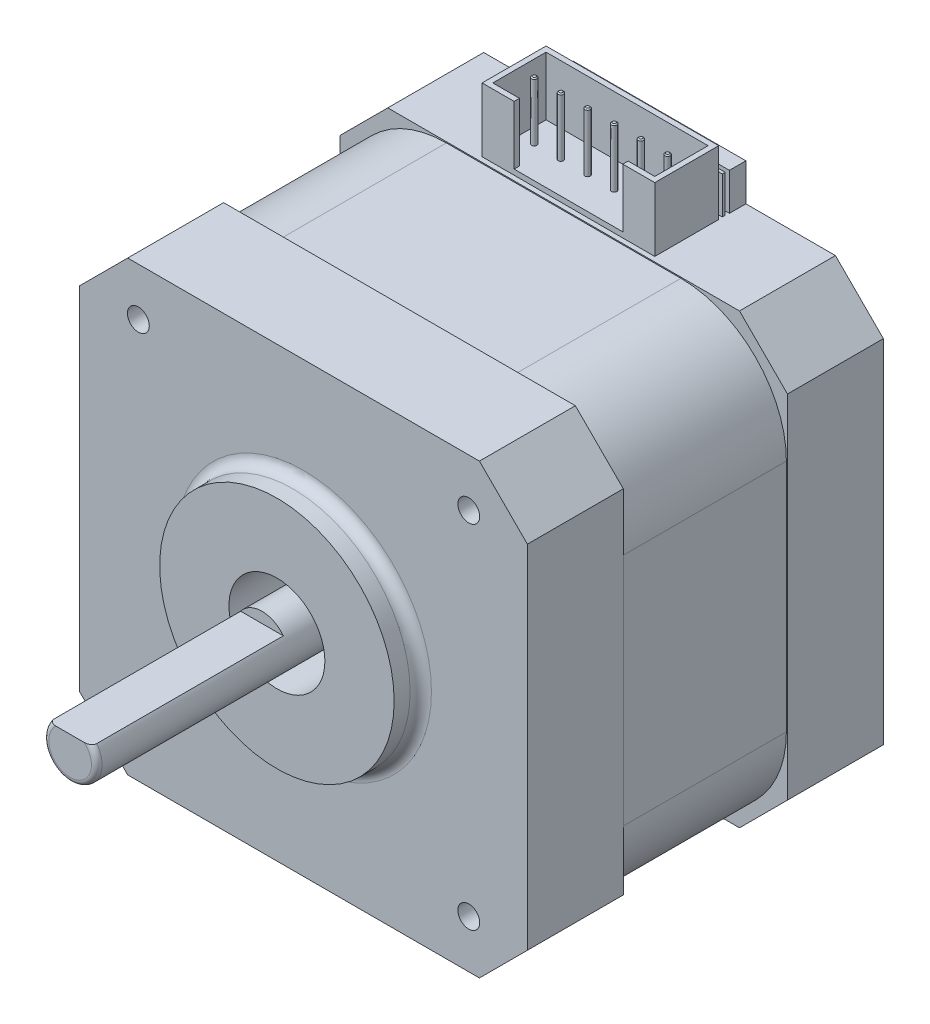
from build123d import *

# Parameters (mm, degrees)
BOSS_EXTRUDE1_DEPTH                = 9
BOSS_EXTRUDE2_DEPTH                = 15.4
BOSS_EXTRUDE3_DEPTH                = 9
SKETCH4_R                          = 4.5
CUT_EXTRUDE1_DEPTH                 = 5
SKETCH5_R                          = 2.5
BOSS_EXTRUDE4_DEPTH                = 26.9
SKETCH6_W                          = 16.2
SKETCH6_H                          = 1.547449217
BOSS_EXTRUDE5_DEPTH                = 3.5
EXTRUDE_THIN4_DEPTH                = 6
BOSS_EXTRUDE7_DEPTH                = 0.5
SKETCH9_W                          = 16.123667198
SKETCH9_H                          = 0.274090176
BOSS_EXTRUDE8_DEPTH                = 3.5
SKETCH10_R                         = 0.25
BOSS_EXTRUDE9_DEPTH                = 5.5
CHAMFER1_SIZE                      = 0.1
SKETCH11_R                         = 11
SKETCH11_R_2                       = 4.5
BOSS_EXTRUDE10_DEPTH               = 2.5
FILLET1_R                          = 1
CUT_EXTRUDE2_DEPTH                 = 18
FILLET2_R                          = 0.5
TAP_DRILL_FOR_M2_5X0_45_TAP2_D     = 2.05
TAP_DRILL_FOR_M2_5X0_45_TAP2_DEPTH = 5
TAP_DRILL_FOR_M2_5X0_45_TAP2_TIP   = 0.615882135


with BuildPart() as part:
    # Sketch1 → Boss-Extrude1 (new body)
    with BuildSketch(Plane.XY):
        Polygon((21, 16.5), (16.5, 21), (-16.5, 21), (-21, 16.5), (-21, -16.5), (-16.5, -21), (16.5, -21), (21, -16.5), align=None)
    extrude(amount=BOSS_EXTRUDE1_DEPTH)

    # Sketch2 → Boss-Extrude2 (add)
    with BuildSketch(Plane.XY.offset(9)):
        with BuildLine():
            Line((11, 20.9), (-11, 20.9))
            ThreePointArc((-11, 20.9), (-18.000357134, 18.000357134), (-20.9, 11))
            Line((-20.9, 11), (-20.9, -11))
            ThreePointArc((-20.9, -11), (-18.000357134, -18.000357134), (-11, -20.9))
            Line((-11, -20.9), (11, -20.9))
            ThreePointArc((11, -20.9), (18.000357134, -18.000357134), (20.9, -11))
            Line((20.9, -11), (20.9, 11))
            ThreePointArc((20.9, 11), (18.000357134, 18.000357134), (11, 20.9))
        make_face()
    extrude(amount=BOSS_EXTRUDE2_DEPTH)

    # Sketch3 → Boss-Extrude3 (add)
    with BuildSketch(Plane.XY.offset(24.4)):
        Polygon((21, -16.5), (21, 16.5), (16.5, 21), (-16.5, 21), (-21, 16.5), (-21, -16.5), (-16.5, -21), (16.5, -21), align=None)
    extrude(amount=BOSS_EXTRUDE3_DEPTH)

    # Sketch4 → Cut-Extrude1 (cut)
    with BuildSketch(Plane.XY.offset(33.4)):
        Circle(SKETCH4_R)
    extrude(amount=-CUT_EXTRUDE1_DEPTH, mode=Mode.SUBTRACT)

    # Sketch5 → Boss-Extrude4 (add)
    with BuildSketch(Plane.XY.offset(28.4)):
        Circle(SKETCH5_R)
    extrude(amount=BOSS_EXTRUDE4_DEPTH)

    # Sketch6 → Boss-Extrude5 (add)
    with BuildSketch(Plane(origin=(0, 21, 0), x_dir=(1, 0, 0), z_dir=(0, 1, 0))):
        with Locations((0, -0.773724609)):
            Rectangle(SKETCH6_W, SKETCH6_H)
    extrude(amount=BOSS_EXTRUDE5_DEPTH)

    # Sketch7 → Extrude-Thin4 (add)
    with BuildSketch(Plane(origin=(0, 21, 0), x_dir=(1, 0, 0), z_dir=(0, 1, 0))):
        Polygon((-5.1, -8.547449217), (-8.1, -8.547449217), (-8.1, -2.547449217), (8.1, -2.547449217), (8.1, -8.547449217), (5.1, -8.547449217), (5.1, -8.047449217), (7.6, -8.047449217), (7.6, -3.047449217), (-7.6, -3.047449217), (-7.6, -8.047449217), (-5.1, -8.047449217), align=None)
    extrude(amount=EXTRUDE_THIN4_DEPTH)

    # Sketch8 → Boss-Extrude7 (add)
    with BuildSketch(Plane(origin=(0, 21, 0), x_dir=(1, 0, 0), z_dir=(0, 1, 0))):
        Polygon((-5.1, -8.047449217), (-5.1, -8.547449217), (5.1, -8.547449217), (5.1, -8.047449217), (7.6, -8.047449217), (7.6, -3.047449217), (-7.6, -3.047449217), (-7.6, -8.047449217), align=None)
    extrude(amount=BOSS_EXTRUDE7_DEPTH)

    # Sketch9 → Boss-Extrude8 (add)
    with BuildSketch(Plane(origin=(0, 21, 0), x_dir=(1, 0, 0), z_dir=(0, 1, 0))):
        with Locations((0, -2.039705449)):
            Rectangle(SKETCH9_W, SKETCH9_H)
    extrude(amount=BOSS_EXTRUDE8_DEPTH)

    # Sketch10 → Boss-Extrude9 (add)
    with BuildSketch(Plane(origin=(0, 21.5, 0), x_dir=(1, 0, 0), z_dir=(0, 1, 0))):
        with Locations((-6.204552759, -5.547449217)):
            Circle(SKETCH10_R)
        with Locations((-3.704552759, -5.547449217)):
            Circle(SKETCH10_R)
        with Locations((-1.204552759, -5.547449217)):
            Circle(SKETCH10_R)
        with Locations((1.295447241, -5.547449217)):
            Circle(SKETCH10_R)
        with Locations((3.795447241, -5.547449217)):
            Circle(SKETCH10_R)
        with Locations((6.295447241, -5.547449217)):
            Circle(SKETCH10_R)
    extrude(amount=BOSS_EXTRUDE9_DEPTH)

    # Chamfer1
    chamfer1_edges = [part.edges().sort_by_distance(p)[0] for p in [
        (-6.454552759, 27, 5.547449217),
        (-3.954552759, 27, 5.547449217),
        (-1.454552759, 27, 5.547449217),
        (1.045447241, 27, 5.547449217),
        (3.545447241, 27, 5.547449217),
        (6.045447241, 27, 5.547449217),
    ]]
    chamfer(chamfer1_edges, length=CHAMFER1_SIZE)

    # Sketch11 → Boss-Extrude10 (add)
    with BuildSketch(Plane.XY.offset(33.4)):
        Circle(SKETCH11_R)
        Circle(SKETCH11_R_2, mode=Mode.SUBTRACT)
    extrude(amount=BOSS_EXTRUDE10_DEPTH)

    # Fillet1
    fillet1_edges = [part.edges().sort_by_distance(p)[0] for p in [
        (-11, 0, 33.4),
    ]]
    fillet(fillet1_edges, radius=FILLET1_R)

    # Sketch12 → Cut-Extrude2 (cut)
    with BuildSketch(Plane.XY.offset(55.3)):
        with BuildLine():
            Line((2, 1.5), (-2, 1.5))
            ThreePointArc((-2, 1.5), (0, 2.5), (2, 1.5))
        make_face()
    extrude(amount=-CUT_EXTRUDE2_DEPTH, mode=Mode.SUBTRACT)

    # Fillet2
    fillet2_edges = [part.edges().sort_by_distance(p)[0] for p in [
        (-0.790569415, -2.371708245, 55.3),
    ]]
    fillet(fillet2_edges, radius=FILLET2_R)

    # Tap Drill for M2.5x0.45 Tap2
    with Locations(Plane.XY.offset(33.4)):
        with Locations((15.5, 16.5), (15.5, -16.5), (-15.5, -16.5), (-15.5, 16.5)):
            Hole(TAP_DRILL_FOR_M2_5X0_45_TAP2_D / 2, depth=TAP_DRILL_FOR_M2_5X0_45_TAP2_DEPTH)
            with Locations((0, 0, -(TAP_DRILL_FOR_M2_5X0_45_TAP2_DEPTH + TAP_DRILL_FOR_M2_5X0_45_TAP2_TIP / 2))):  # 118° drill point
                Cone(0, TAP_DRILL_FOR_M2_5X0_45_TAP2_D / 2, TAP_DRILL_FOR_M2_5X0_45_TAP2_TIP, mode=Mode.SUBTRACT)


solid = part.part
